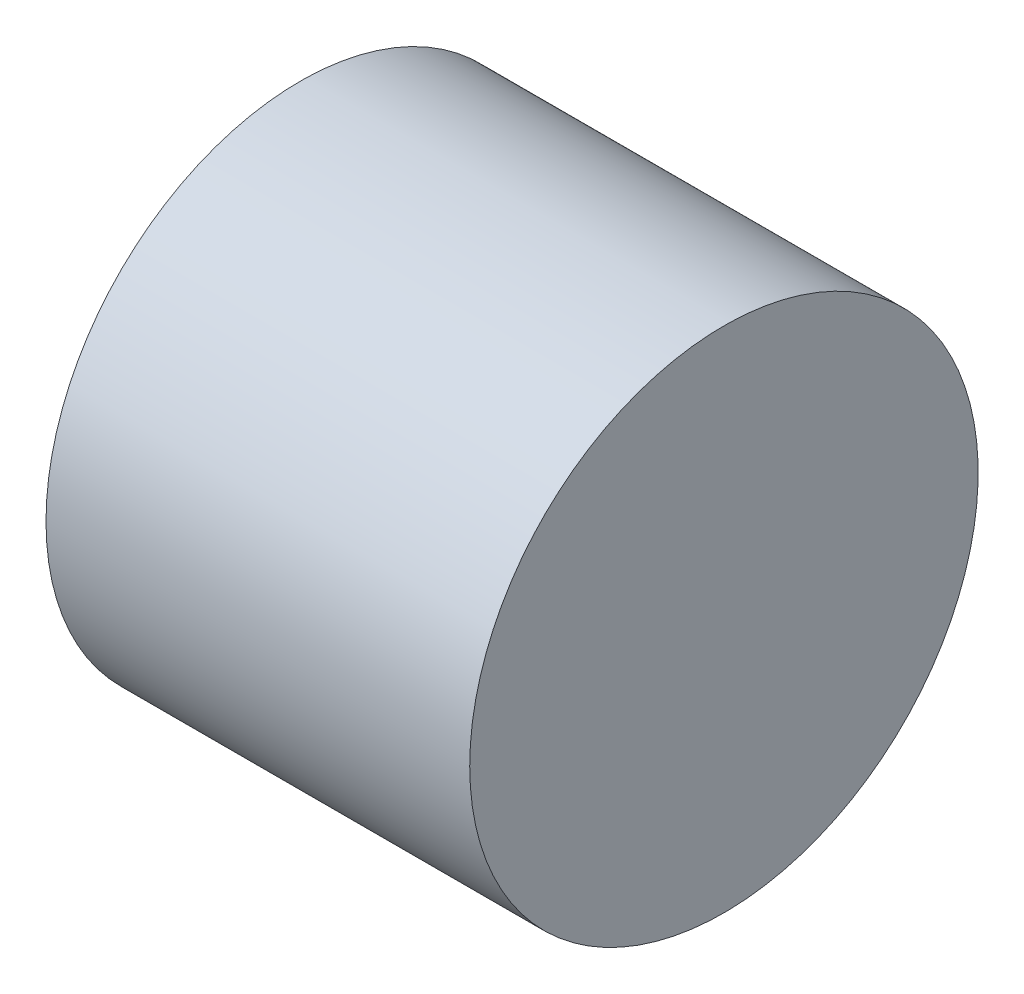
from build123d import *

# Parameters (mm, degrees)
CROQUIS1_W = 5
CROQUIS1_H = 3


with BuildPart() as part:
    # Croquis1 → Revolución1 (revolve)
    with BuildSketch(Plane(origin=(0, 0, 0), x_dir=(1, 0, 0), z_dir=(0, 1, 0))):
        with Locations((0, 1.5)):
            Rectangle(CROQUIS1_W, CROQUIS1_H)
    revolve(axis=Axis((-5.17974618, 0, 0), (1, 0, 0)))


solid = part.part
